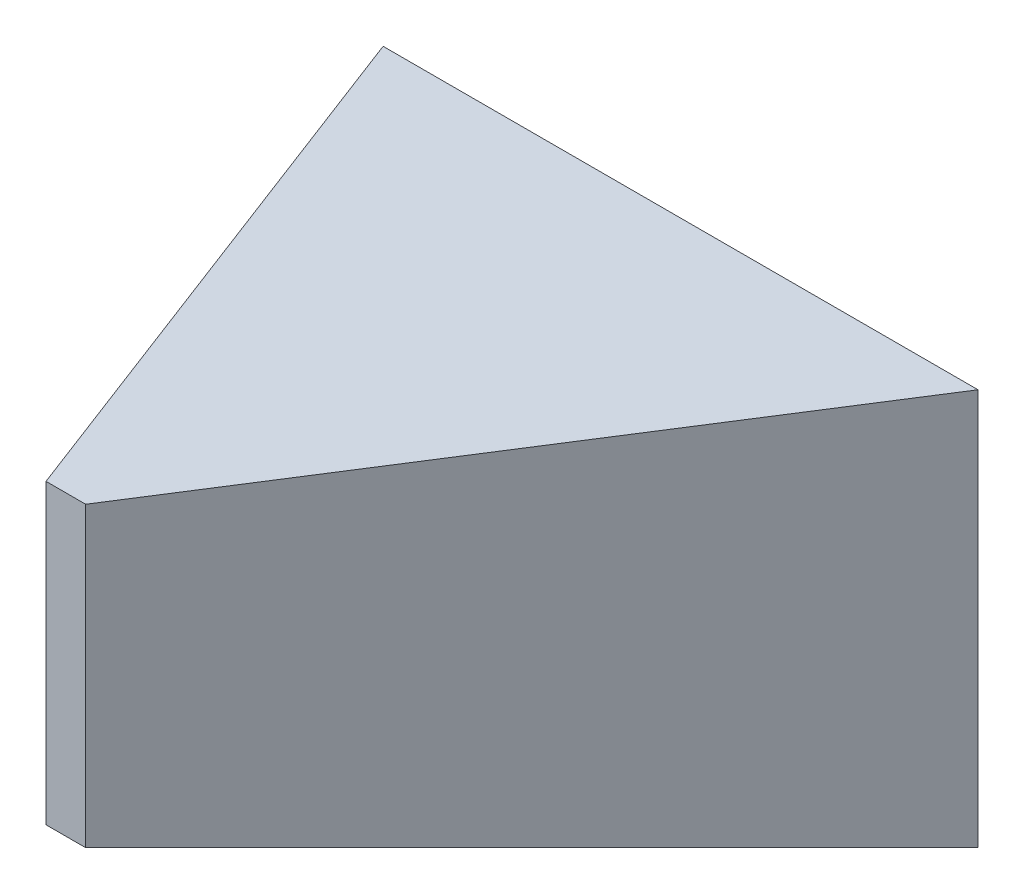
from build123d import *

# Parameters (mm, degrees)
SKETCH2_W = 2
SKETCH2_H = 15
SKETCH1_W = 30
SKETCH1_H = 20


with BuildPart() as part:
    # Sketch2 → Loft2 section 0
    with BuildSketch(Plane.XY.offset(25)):
        with Locations((9, 10)):
            Rectangle(SKETCH2_W, SKETCH2_H)
    # Sketch1 → Loft2 section 1
    with BuildSketch(Plane.XY):
        with Locations((15, 10)):
            Rectangle(SKETCH1_W, SKETCH1_H)
    loft()


solid = part.part
